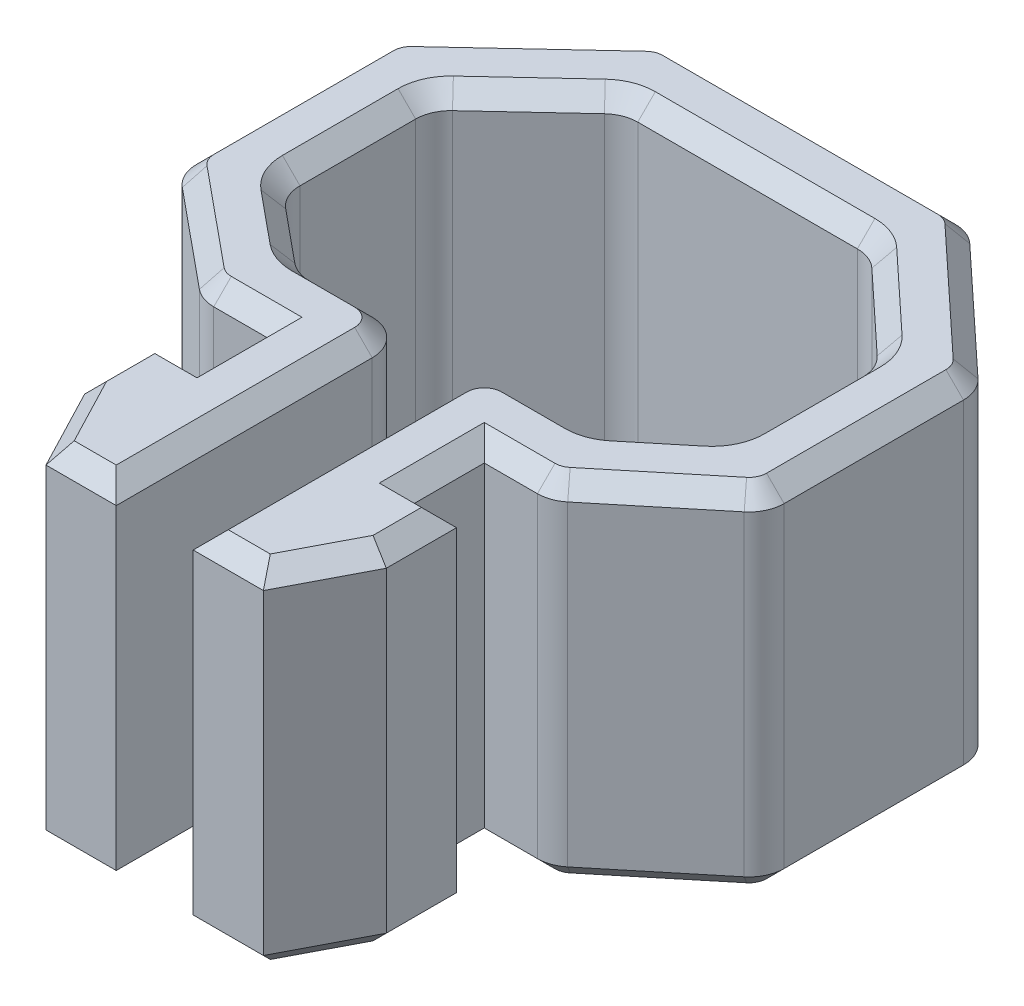
from build123d import *

# Parameters (mm, degrees)
BOSS_EXTRUDE1_DEPTH = 10
FILLET1_R           = 1
CHAMFER1_SIZE       = 0.5


with BuildPart() as part:
    # Sketch1 → Boss-Extrude1 (new body)
    with BuildSketch(Plane(origin=(0, 0, 0), x_dir=(1, 0, 0), z_dir=(0, 1, 0))):
        Polygon((2.19, 0), (4.19, 0), (5.39, 2.3), (5.39, 4.3), (4.19, 4.3), (4.19, 6.29), (6.062127702, 6.29), (9.46014997, 9.086335224), (9.46014997, 15.100590628), (5.402376873, 18.882324593), (-3.212376873, 18.882324593), (-7.27014997, 15.100590628), (-7.27014997, 9.086335224), (-3.872127702, 6.29), (-2, 6.29), (-2, 4.3), (-3.2, 4.3), (-3.2, 2.3), (-2, 0), (0, 0), (0, 8.29), (-3.155, 8.29), (-5.27014997, 10.030620837), (-5.27014997, 14.230620837), (-2.424891086, 16.882324593), (4.614891086, 16.882324593), (7.46014997, 14.230620837), (7.46014997, 10.030620837), (5.345, 8.29), (2.19, 8.29), align=None)
    extrude(amount=BOSS_EXTRUDE1_DEPTH)

    # Fillet1
    fillet1_edges = [part.edges().sort_by_distance(p)[0] for p in [
        (5.345, 5, -8.29),
        (7.46014997, 5, -10.030620837),
        (7.46014997, 5, -14.230620837),
        (4.614891086, 5, -16.882324593),
        (-2.424891086, 5, -16.882324593),
        (-5.27014997, 5, -14.230620837),
        (-5.27014997, 5, -10.030620837),
        (-3.155, 5, -8.29),
        (0, 5, -8.29),
        (-3.872127702, 5, -6.29),
        (-7.27014997, 5, -9.086335224),
        (-7.27014997, 5, -15.100590628),
        (-3.212376873, 5, -18.882324593),
        (5.402376873, 5, -18.882324593),
        (9.46014997, 5, -15.100590628),
        (9.46014997, 5, -9.086335224),
        (6.062127702, 5, -6.29),
        (2.19, 5, -8.29),
    ]]
    fillet(fillet1_edges, radius=FILLET1_R)

    # Chamfer1
    chamfer1_edges = [part.edges().sort_by_distance(p)[0] for p in [
        (9.364426343, 0, -9.131530446),
        (9.377152184, 0, -15.064487844),
        (5.375000217, 0, -18.812795323),
        (-3.185000217, 0, -18.812795323),
        (-7.187152184, 0, -15.064487844),
        (-0.292893219, 0, -7.997106781),
        (-3.851086274, 0, -6.348682512),
        (-7.174426343, 0, -9.131530446),
        (-7.27014997, 10, -12.112041882),
        (4.088218075, 10, -8.29),
        (2.19, 10, -3.645),
        (4.946781925, 10, -6.29),
        (7.71728843, 10, -7.652081788),
        (9.46014997, 10, -12.112041882),
        (7.416178096, 10, -17.005516722),
        (1.095, 10, -18.882324593),
        (-5.226178096, 10, -17.005516722),
        (-2.756781925, 10, -6.29),
        (0, 10, -3.645),
        (-1.898218075, 10, -8.29),
        (-4.168724579, 10, -9.124224594),
        (-5.27014997, 10, -12.149199793),
        (-3.832435203, 10, -15.570531827),
        (1.095, 10, -16.882324593),
        (6.022435203, 10, -15.570531827),
        (7.46014997, 10, -12.149199793),
        (6.358724579, 10, -9.124224594),
        (2.482893219, 10, -7.997106781),
        (6.041086274, 10, -6.348682512),
        (9.364426343, 10, -9.131530446),
        (9.377152184, 10, -15.064487844),
        (5.375000217, 10, -18.812795323),
        (-3.185000217, 10, -18.812795323),
        (-7.187152184, 10, -15.064487844),
        (-0.292893219, 10, -7.997106781),
        (-3.851086274, 10, -6.348682512),
        (-7.174426343, 10, -9.131530446),
        (3.19, 10, 0),
        (-3.133958573, 0, -8.348682512),
        (-3.133958573, 10, -8.348682512),
        (-5.174426343, 0, -10.075816059),
        (-5.174426343, 10, -10.075816059),
        (-5.187152184, 0, -14.194518054),
        (-5.187152184, 10, -14.194518054),
        (-2.39751443, 0, -16.812795323),
        (-2.39751443, 10, -16.812795323),
        (4.58751443, 0, -16.812795323),
        (4.58751443, 10, -16.812795323),
        (5.323958573, 0, -8.348682512),
        (5.323958573, 10, -8.348682512),
        (7.364426343, 0, -10.075816059),
        (7.364426343, 10, -10.075816059),
        (7.377152184, 0, -14.194518054),
        (7.377152184, 10, -14.194518054),
        (4.79, 10, -1.15),
        (5.39, 10, -3.3),
        (4.79, 10, -4.3),
        (4.19, 10, -5.295),
        (-1, 0, 0),
        (-2.6, 0, -1.15),
        (-3.2, 0, -3.3),
        (-2.6, 0, -4.3),
        (-2, 0, -5.295),
        (4.19, 0, -5.295),
        (4.79, 0, -4.3),
        (5.39, 0, -3.3),
        (4.79, 0, -1.15),
        (3.19, 0, 0),
        (-2, 10, -5.295),
        (-2.6, 10, -4.3),
        (-3.2, 10, -3.3),
        (-2.6, 10, -1.15),
        (-1, 10, 0),
        (-5.52728843, 0, -7.652081788),
        (-5.52728843, 10, -7.652081788),
        (4.088218075, 0, -8.29),
        (6.358724579, 0, -9.124224594),
        (7.46014997, 0, -12.149199793),
        (6.022435203, 0, -15.570531827),
        (1.095, 0, -16.882324593),
        (-3.832435203, 0, -15.570531827),
        (-5.27014997, 0, -12.149199793),
        (-4.168724579, 0, -9.124224594),
        (-1.898218075, 0, -8.29),
        (0, 0, -3.645),
        (-2.756781925, 0, -6.29),
        (-7.27014997, 0, -12.112041882),
        (-5.226178096, 0, -17.005516722),
        (1.095, 0, -18.882324593),
        (7.416178096, 0, -17.005516722),
        (9.46014997, 0, -12.112041882),
        (7.71728843, 0, -7.652081788),
        (4.946781925, 0, -6.29),
        (2.19, 0, -3.645),
        (2.482893219, 0, -7.997106781),
        (6.041086274, 0, -6.348682512),
    ]]
    chamfer(chamfer1_edges, length=CHAMFER1_SIZE)


solid = part.part
